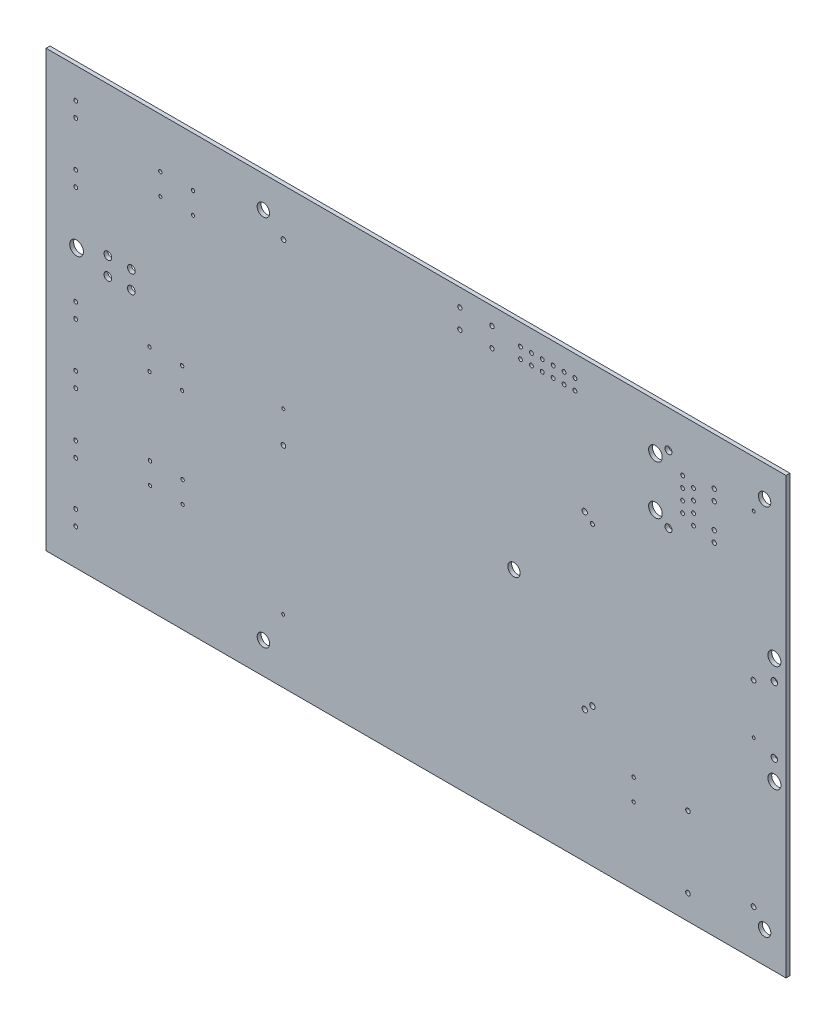
from build123d import *

# Parameters (mm, degrees)
SKETCH1_W                  = 172.72
SKETCH1_H                  = 101.6
SKETCH1_R                  = 0.3499993
SKETCH1_R_2                = 0.50999898
SKETCH1_R_3                = 0.44500038
SKETCH1_R_4                = 0.4499991
SKETCH1_R_5                = 0.81499964
SKETCH1_R_6                = 1.58999936
SKETCH1_R_7                = 1.524
SKETCH1_R_8                = 0.7493
SKETCH1_R_9                = 0.5499989
SKETCH1_R_10               = 0.5334
SKETCH1_R_11               = 0.62500002
SKETCH1_R_12               = 0.47500032
SKETCH1_R_13               = 0.3999992
SKETCH1_R_14               = 0.37500052
SKETCH1_R_15               = 0.49500028
SKETCH1_R_16               = 0.8999982
SKETCH1_R_17               = 1.59999934
BOSS_EXTRUDE1_DEPTH        = 0.90932
M2_5_CLEARANCE_HOLE1_D     = 2.9
M2_5_CLEARANCE_HOLE1_DEPTH = 25.4
M2_5_CLEARANCE_HOLE1_TIP   = 0.871247898


with BuildPart() as part:
    # Sketch1 → Boss-Extrude1 (new body)
    with BuildSketch(Plane.XY.offset(0.90932)):
        with Locations((200.66, 124.46)):
            Rectangle(SKETCH1_W, SKETCH1_H)
        with Locations((279.48999982, 164.28500036)):
            Circle(SKETCH1_R, mode=Mode.SUBTRACT)
        with Locations((270.256, 164.211)):
            Circle(SKETCH1_R_2, mode=Mode.SUBTRACT)
        with Locations((265.43, 161.925)):
            Circle(SKETCH1_R_3, mode=Mode.SUBTRACT)
        with Locations((262.89, 163.195)):
            Circle(SKETCH1_R_3, mode=Mode.SUBTRACT)
        with Locations((270.256, 161.671)):
            Circle(SKETCH1_R_2, mode=Mode.SUBTRACT)
        with Locations((265.43, 156.845)):
            Circle(SKETCH1_R_3, mode=Mode.SUBTRACT)
        with Locations((265.43, 159.385)):
            Circle(SKETCH1_R_3, mode=Mode.SUBTRACT)
        with Locations((270.256, 155.829)):
            Circle(SKETCH1_R_2, mode=Mode.SUBTRACT)
        with Locations((262.89, 160.655)):
            Circle(SKETCH1_R_3, mode=Mode.SUBTRACT)
        with Locations((262.89, 158.115)):
            Circle(SKETCH1_R_3, mode=Mode.SUBTRACT)
        with Locations((237.744, 167.767)):
            Circle(SKETCH1_R_4, mode=Mode.SUBTRACT)
        with Locations((237.744, 170.307)):
            Circle(SKETCH1_R_4, mode=Mode.SUBTRACT)
        with Locations((235.204, 167.767)):
            Circle(SKETCH1_R_4, mode=Mode.SUBTRACT)
        with Locations((232.664, 170.307)):
            Circle(SKETCH1_R_4, mode=Mode.SUBTRACT)
        with Locations((230.124, 170.307)):
            Circle(SKETCH1_R_4, mode=Mode.SUBTRACT)
        with Locations((235.204, 170.307)):
            Circle(SKETCH1_R_4, mode=Mode.SUBTRACT)
        with Locations((259.588, 166.624)):
            Circle(SKETCH1_R_5, mode=Mode.SUBTRACT)
        with Locations((232.664, 167.767)):
            Circle(SKETCH1_R_4, mode=Mode.SUBTRACT)
        with Locations((256.54, 164.465)):
            Circle(SKETCH1_R_6, mode=Mode.SUBTRACT)
        with Locations((227.584, 167.767)):
            Circle(SKETCH1_R_4, mode=Mode.SUBTRACT)
        with Locations((230.124, 167.767)):
            Circle(SKETCH1_R_4, mode=Mode.SUBTRACT)
        with Locations((284.3022, 136.906)):
            Circle(SKETCH1_R_7, mode=Mode.SUBTRACT)
        with Locations((284.3022, 132.207)):
            Circle(SKETCH1_R_8, mode=Mode.SUBTRACT)
        with Locations((279.48999982, 118.48500052)):
            Circle(SKETCH1_R, mode=Mode.SUBTRACT)
        with Locations((270.256, 153.289)):
            Circle(SKETCH1_R_2, mode=Mode.SUBTRACT)
        with Locations((265.43, 154.305)):
            Circle(SKETCH1_R_3, mode=Mode.SUBTRACT)
        with Locations((279.43999992, 130.08500018)):
            Circle(SKETCH1_R_9, mode=Mode.SUBTRACT)
        with Locations((284.3022, 112.014)):
            Circle(SKETCH1_R_7, mode=Mode.SUBTRACT)
        with Locations((284.3022, 116.713)):
            Circle(SKETCH1_R_8, mode=Mode.SUBTRACT)
        with Locations((279.43999992, 84.28500034)):
            Circle(SKETCH1_R_9, mode=Mode.SUBTRACT)
        with Locations((264.1346, 79.375)):
            Circle(SKETCH1_R_10, mode=Mode.SUBTRACT)
        with Locations((262.89, 155.575)):
            Circle(SKETCH1_R_3, mode=Mode.SUBTRACT)
        with Locations((256.54, 153.035)):
            Circle(SKETCH1_R_6, mode=Mode.SUBTRACT)
        with Locations((259.588, 150.876)):
            Circle(SKETCH1_R_5, mode=Mode.SUBTRACT)
        with Locations((240.03, 144.46000064)):
            Circle(SKETCH1_R_11, mode=Mode.SUBTRACT)
        with Locations((241.82999894, 142.85999876)):
            Circle(SKETCH1_R_12, mode=Mode.SUBTRACT)
        with Locations((264.1346, 96.0374)):
            Circle(SKETCH1_R_10, mode=Mode.SUBTRACT)
        with Locations((251.46, 96.48000008)):
            Circle(SKETCH1_R_13, mode=Mode.SUBTRACT)
        with Locations((251.46, 91.47999992)):
            Circle(SKETCH1_R_14, mode=Mode.SUBTRACT)
        with Locations((241.82999894, 106.06000124)):
            Circle(SKETCH1_R_11, mode=Mode.SUBTRACT)
        with Locations((240.03, 104.45999936)):
            Circle(SKETCH1_R_11, mode=Mode.SUBTRACT)
        with Locations((227.584, 170.307)):
            Circle(SKETCH1_R_4, mode=Mode.SUBTRACT)
        with Locations((225.044, 170.307)):
            Circle(SKETCH1_R_4, mode=Mode.SUBTRACT)
        with Locations((225.044, 167.767)):
            Circle(SKETCH1_R_4, mode=Mode.SUBTRACT)
        with Locations((218.38000012, 171.16000058)):
            Circle(SKETCH1_R_15, mode=Mode.SUBTRACT)
        with Locations((210.87999988, 171.16000058)):
            Circle(SKETCH1_R_15, mode=Mode.SUBTRACT)
        with Locations((218.38000012, 166.65999942)):
            Circle(SKETCH1_R_15, mode=Mode.SUBTRACT)
        with Locations((210.87999988, 166.65999942)):
            Circle(SKETCH1_R_15, mode=Mode.SUBTRACT)
        with Locations((169.7150022, 164.28500036)):
            Circle(SKETCH1_R_9, mode=Mode.SUBTRACT)
        with Locations((148.59, 163.63659932)):
            Circle(SKETCH1_R_13, mode=Mode.SUBTRACT)
        with Locations((148.59, 158.63659916)):
            Circle(SKETCH1_R_14, mode=Mode.SUBTRACT)
        with Locations((140.97, 163.63659932)):
            Circle(SKETCH1_R_13, mode=Mode.SUBTRACT)
        with Locations((121.20999888, 168.11999904)):
            Circle(SKETCH1_R_4, mode=Mode.SUBTRACT)
        with Locations((140.97, 158.63659916)):
            Circle(SKETCH1_R_14, mode=Mode.SUBTRACT)
        with Locations((121.20999888, 164.62000096)):
            Circle(SKETCH1_R_4, mode=Mode.SUBTRACT)
        with Locations((121.20999888, 154.14999904)):
            Circle(SKETCH1_R_4, mode=Mode.SUBTRACT)
        with Locations((134.2119998, 140.53000088)):
            Circle(SKETCH1_R_16, mode=Mode.SUBTRACT)
        with Locations((128.71200064, 140.53000088)):
            Circle(SKETCH1_R_16, mode=Mode.SUBTRACT)
        with Locations((134.2119998, 136.32999912)):
            Circle(SKETCH1_R_16, mode=Mode.SUBTRACT)
        with Locations((121.20999888, 150.65000096)):
            Circle(SKETCH1_R_4, mode=Mode.SUBTRACT)
        with Locations((121.412, 138.43)):
            Circle(SKETCH1_R_17, mode=Mode.SUBTRACT)
        with Locations((169.69000098, 122.68499974)):
            Circle(SKETCH1_R_9, mode=Mode.SUBTRACT)
        with Locations((169.6650023, 130.08500018)):
            Circle(SKETCH1_R, mode=Mode.SUBTRACT)
        with Locations((146.177, 103.99739932)):
            Circle(SKETCH1_R_13, mode=Mode.SUBTRACT)
        with Locations((146.05, 126.96000008)):
            Circle(SKETCH1_R_13, mode=Mode.SUBTRACT)
        with Locations((138.43, 126.96000008)):
            Circle(SKETCH1_R_13, mode=Mode.SUBTRACT)
        with Locations((146.05, 121.95999992)):
            Circle(SKETCH1_R_14, mode=Mode.SUBTRACT)
        with Locations((169.64000108, 88.48499956)):
            Circle(SKETCH1_R, mode=Mode.SUBTRACT)
        with Locations((146.177, 98.99739916)):
            Circle(SKETCH1_R_14, mode=Mode.SUBTRACT)
        with Locations((138.557, 103.99739932)):
            Circle(SKETCH1_R_13, mode=Mode.SUBTRACT)
        with Locations((138.557, 98.99739916)):
            Circle(SKETCH1_R_14, mode=Mode.SUBTRACT)
        with Locations((128.71200064, 136.32999912)):
            Circle(SKETCH1_R_16, mode=Mode.SUBTRACT)
        with Locations((121.20999888, 127.47999904)):
            Circle(SKETCH1_R_4, mode=Mode.SUBTRACT)
        with Locations((138.43, 121.95999992)):
            Circle(SKETCH1_R_14, mode=Mode.SUBTRACT)
        with Locations((121.20999888, 123.98000096)):
            Circle(SKETCH1_R_4, mode=Mode.SUBTRACT)
        with Locations((121.20999888, 113.50999904)):
            Circle(SKETCH1_R_4, mode=Mode.SUBTRACT)
        with Locations((121.20999888, 85.56999904)):
            Circle(SKETCH1_R_4, mode=Mode.SUBTRACT)
        with Locations((121.20999888, 95.91300096)):
            Circle(SKETCH1_R_4, mode=Mode.SUBTRACT)
        with Locations((121.20999888, 82.07000096)):
            Circle(SKETCH1_R_4, mode=Mode.SUBTRACT)
        with Locations((121.20999888, 110.01000096)):
            Circle(SKETCH1_R_4, mode=Mode.SUBTRACT)
        with Locations((121.20999888, 99.41299904)):
            Circle(SKETCH1_R_4, mode=Mode.SUBTRACT)
    extrude(amount=-BOSS_EXTRUDE1_DEPTH)

    # M2.5 Clearance Hole1
    with Locations(Plane.XY.offset(0.90932)):
        with Locations((282.02, 167.96), (282.02, 80.96), (165.02, 80.96), (165.02, 167.96), (223.52, 124.46)):
            Hole(M2_5_CLEARANCE_HOLE1_D / 2, depth=M2_5_CLEARANCE_HOLE1_DEPTH)
            with Locations((0, 0, -(M2_5_CLEARANCE_HOLE1_DEPTH + M2_5_CLEARANCE_HOLE1_TIP / 2))):  # 118° drill point
                Cone(0, M2_5_CLEARANCE_HOLE1_D / 2, M2_5_CLEARANCE_HOLE1_TIP, mode=Mode.SUBTRACT)


solid = part.part
